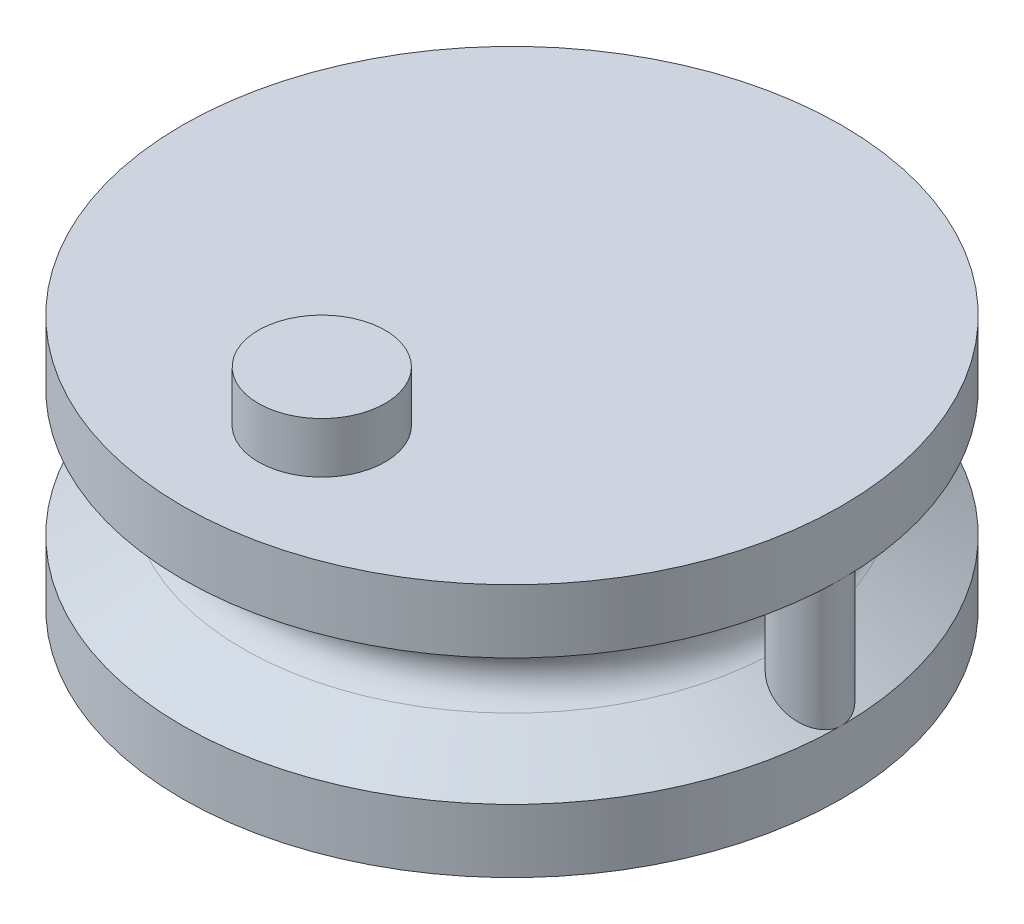
from build123d import *

# Parameters (mm, degrees)
SKETCH1_R           = 10
BOSS_EXTRUDE1_DEPTH = 10
SKETCH3_R           = 5
CUT_EXTRUDE1_DEPTH  = 5
SKETCH4_R           = 2.5
BOSS_EXTRUDE2_DEPTH = 2
SKETCH5_R           = 1.25
BOSS_EXTRUDE3_DEPTH = 10


with BuildPart() as part:
    # Sketch1 → Boss-Extrude1 (new body)
    with BuildSketch(Plane(origin=(0, 0, 0), x_dir=(1, 0, 0), z_dir=(0, 1, 0))):
        Circle(SKETCH1_R)
    extrude(amount=BOSS_EXTRUDE1_DEPTH)

    # Sketch2 → Revolve1 (revolve)
    with BuildSketch(Plane(origin=(0, 0, 0), x_dir=(0, 0, -1), z_dir=(1, 0, 0))):
        with BuildLine():
            Line((10, 10), (13, 10))
            Line((13, 10), (13, 7.5))
            Line((13, 7.5), (10.60943551, 6.073395143))
            ThreePointArc((10.60943551, 6.073395143), (10, 5), (10.60943551, 3.926604857))
            Line((10.60943551, 3.926604857), (13, 2.5))
            Line((13, 2.5), (13, 0))
            Line((13, 0), (10, 0))
            Line((10, 0), (9.25, 0))
            Line((9.25, 0), (9.25, 10))
            Line((9.25, 10), (10, 10))
        make_face()
    revolve(axis=Axis((0, 10, 0), (0, -1, 0)))

    # Sketch3 → Cut-Extrude1 (cut)
    with BuildSketch(Plane.XZ):
        Circle(SKETCH3_R)
    extrude(amount=-CUT_EXTRUDE1_DEPTH, mode=Mode.SUBTRACT)

    # Sketch4 → Boss-Extrude2 (add)
    with BuildSketch(Plane(origin=(0, 10, 0), x_dir=(1, 0, 0), z_dir=(0, 1, 0))):
        with Locations((0, -7.5)):
            Circle(SKETCH4_R)
    extrude(amount=BOSS_EXTRUDE2_DEPTH)

    # Sketch5 → Boss-Extrude3 (add)
    with BuildSketch(Plane(origin=(0, 10, 0), x_dir=(1, 0, 0), z_dir=(0, 1, 0))):
        with Locations((11.75, 0)):
            Circle(SKETCH5_R)
    extrude(amount=-BOSS_EXTRUDE3_DEPTH)


solid = part.part
